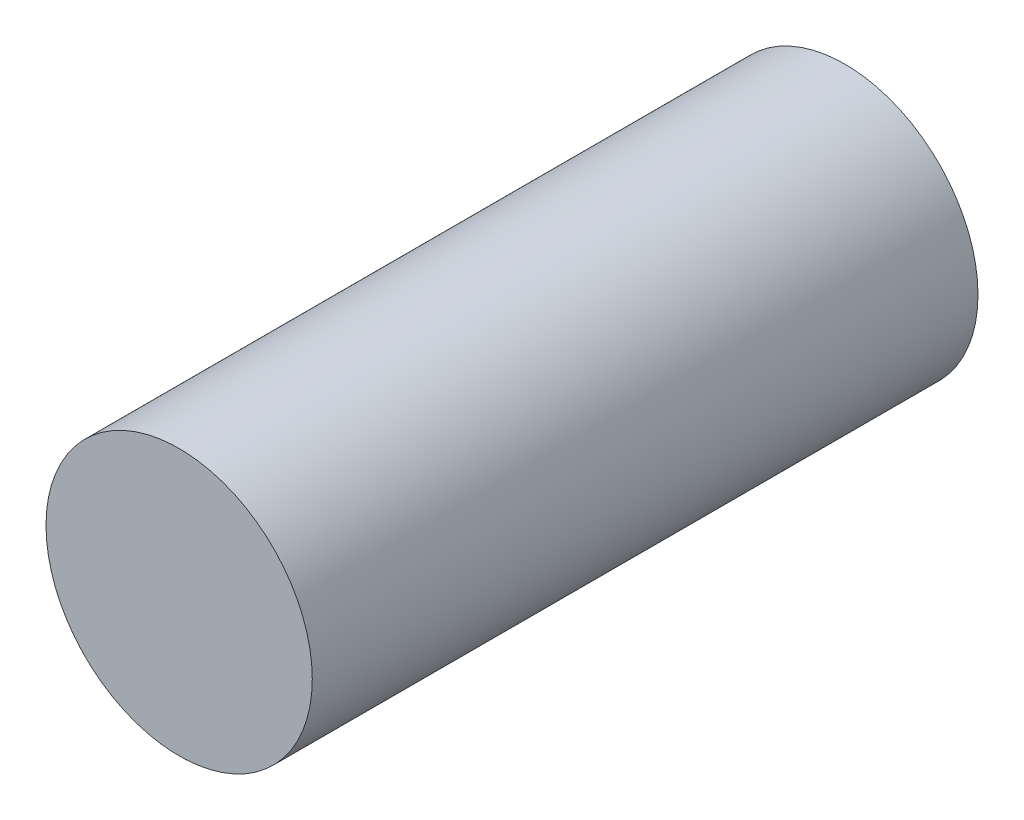
from build123d import *

# Parameters (mm, degrees)
SKETCH1_R           = 4
BOSS_EXTRUDE2_DEPTH = 20
SKETCH3_R           = 1.5
CUT_EXTRUDE2_DEPTH  = 3


with BuildPart() as part:
    # Sketch1 → Boss-Extrude2 (new body)
    with BuildSketch(Plane.XY):
        with Locations((-4.526730855, -2.185903659)):
            Circle(SKETCH1_R)
    extrude(amount=BOSS_EXTRUDE2_DEPTH)

    # Sketch3 → Cut-Extrude2 (cut)
    with BuildSketch(Plane(origin=(0, 0, 0), x_dir=(-1, 0, 0), z_dir=(0, 0, -1))):
        with Locations((4.880055624, -2.040710346)):
            Circle(SKETCH3_R)
    extrude(amount=-CUT_EXTRUDE2_DEPTH, mode=Mode.SUBTRACT)


solid = part.part
